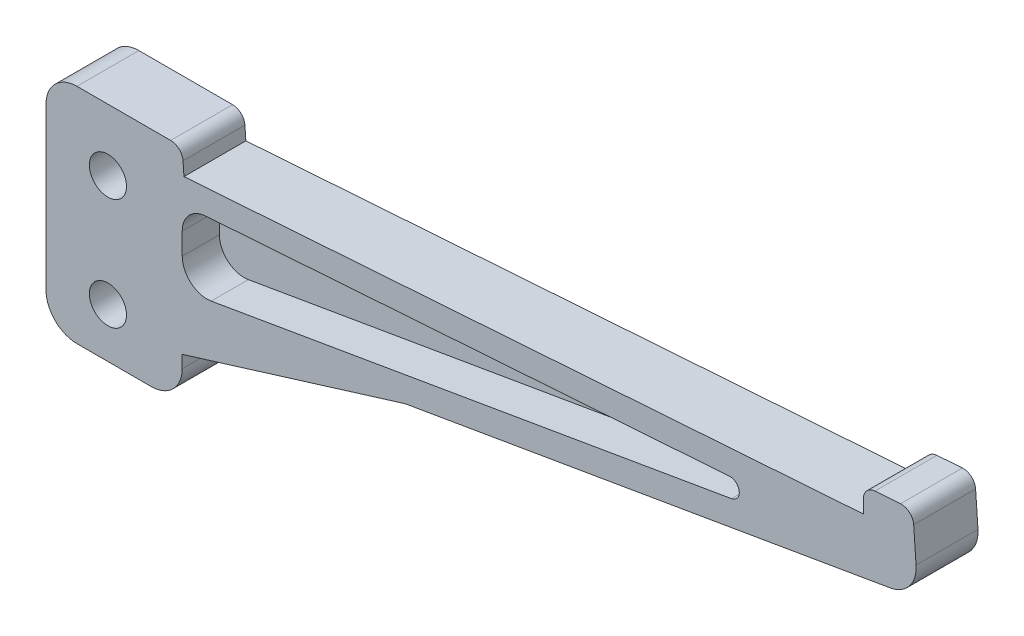
from build123d import *

# Parameters (mm, degrees)
SKETCH1_R           = 3
BOSS_EXTRUDE1_DEPTH = 10
CUT_EXTRUDE1_DEPTH  = 6
BOSS_EXTRUDE2_DEPTH = 10


with BuildPart() as part:
    # Sketch1 → Boss-Extrude1 (new body)
    with BuildSketch(Plane.XY):
        with BuildLine():
            Line((-5, 10), (10.134969828, 10))
            ThreePointArc((10.134969828, 10), (11.498966548, 9.462707403), (12.130097928, 8.139512947))
            Line((12.130097928, 8.139512947), (12.279025895, 6.009743799))
            Line((12.279025895, 6.009743799), (122.011071424, 13.682955911))
            Line((122.011071424, 13.682955911), (122.011071424, 15.827693331))
            ThreePointArc((122.011071424, 15.827693331), (122.54836402, 17.191690051), (123.871558476, 17.822821431))
            Line((123.871558476, 17.822821431), (127.996455725, 18.111262346))
            ThreePointArc((127.996455725, 18.111262346), (129.448086731, 17.625553406), (130.131096773, 16.255647193))
            Line((130.131096773, 16.255647193), (130.513028814, 10.79376454))
            ThreePointArc((130.513028814, 10.79376454), (129.45752894, 7.356802052), (126.3687377, 5.516649939))
            Line((126.3687377, 5.516649939), (12, -14.058605554))
            Line((12, -14.058605554), (12, -21))
            ThreePointArc((12, -21), (10.535533906, -24.535533906), (7, -26))
            Line((7, -26), (-5, -26))
            ThreePointArc((-5, -26), (-8.535533906, -24.535533906), (-10, -21))
            Line((-10, -21), (-10, 5))
            ThreePointArc((-10, 5), (-8.535533906, 8.535533906), (-5, 10))
        make_face()
        Circle(SKETCH1_R, mode=Mode.SUBTRACT)
        with Locations((0, -18)):
            Circle(SKETCH1_R, mode=Mode.SUBTRACT)
    extrude(amount=BOSS_EXTRUDE1_DEPTH)

    # Sketch2 → Cut-Extrude1 (cut)
    with BuildSketch(Plane.XY.offset(10)):
        with BuildLine():
            Line((12, -5.257633034), (12, -1.749595529))
            ThreePointArc((12, -1.749595529), (13.074585194, 0.978397911), (15.720974105, 2.240660672))
            Line((15.720974105, 2.240660672), (100.359457674, 8.159159996))
            ThreePointArc((100.359457674, 8.159159996), (101.953365437, 6.84188311), (100.717151126, 5.18431425))
            Line((100.717151126, 5.18431425), (16.67482331, -9.20029882))
            ThreePointArc((16.67482331, -9.20029882), (13.421172092, -8.31535222), (12, -5.257633034))
        make_face()
    extrude(amount=-CUT_EXTRUDE1_DEPTH, mode=Mode.SUBTRACT)

    # Sketch4 → Boss-Extrude2 (add)
    with BuildSketch(Plane.XY.offset(10)):
        Polygon((12, -18.990256201), (48, -7.896876292), (12, -14.058605554), align=None)
    extrude(amount=-BOSS_EXTRUDE2_DEPTH)


solid = part.part
